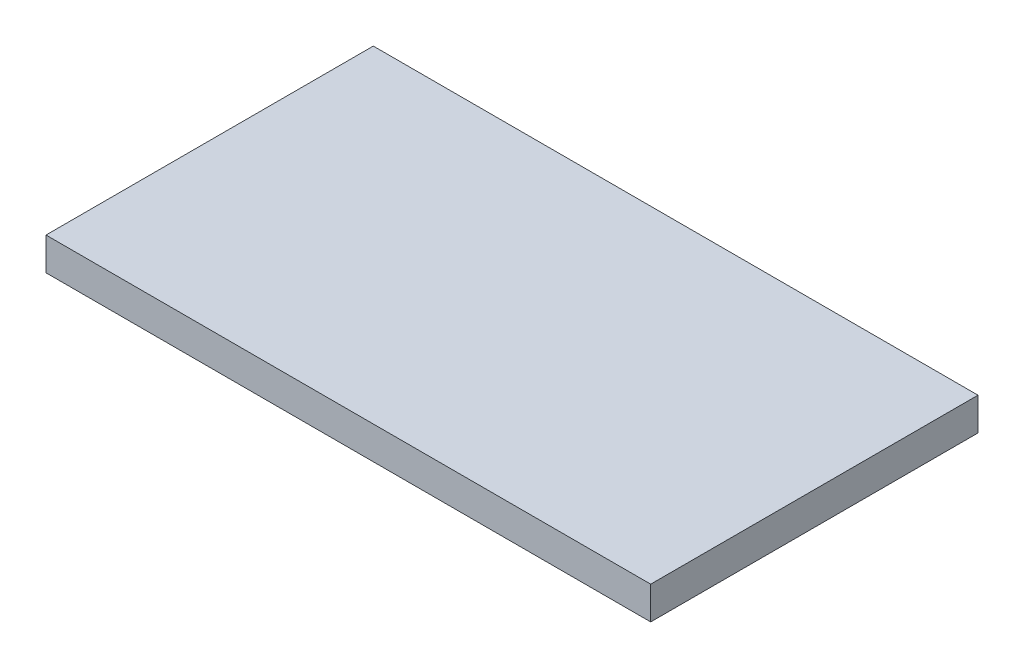
from build123d import *

# Parameters (mm, degrees)
SKETCH2_W           = 184.75
SKETCH2_H           = 100
BOSS_EXTRUDE1_DEPTH = 10


with BuildPart() as part:
    # Sketch2 → Boss-Extrude1 (new body)
    with BuildSketch(Plane(origin=(0, 0, 0), x_dir=(1, 0, 0), z_dir=(0, 1, 0))):
        Rectangle(SKETCH2_W, SKETCH2_H)
    extrude(amount=BOSS_EXTRUDE1_DEPTH)


solid = part.part
